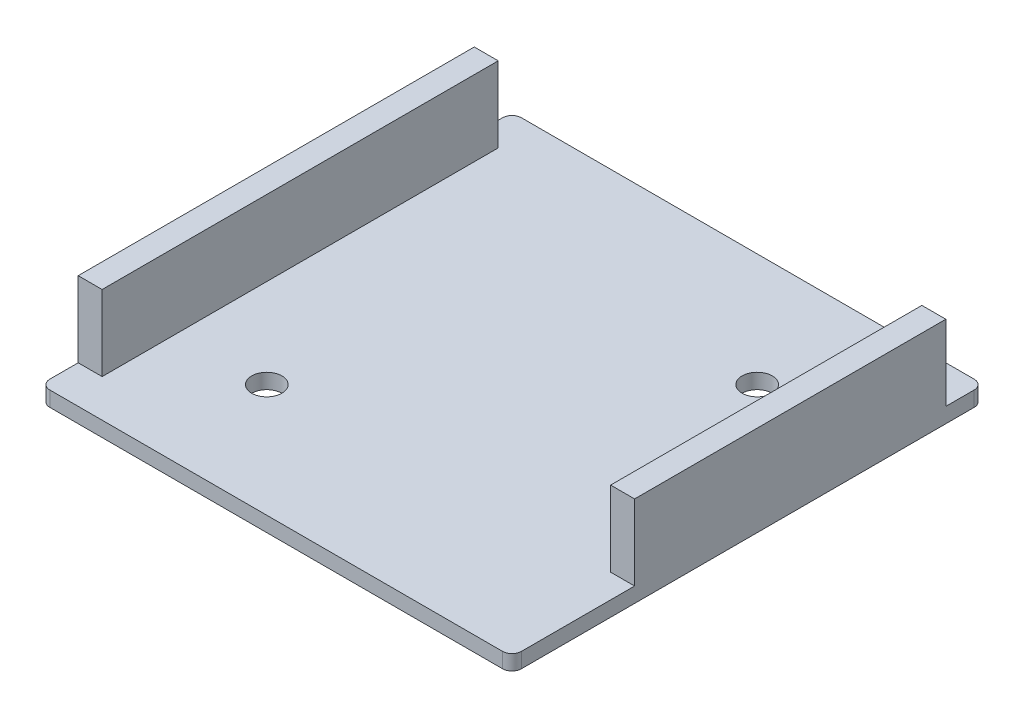
from build123d import *

# Parameters (mm, degrees)
SKETCH1_W           = 50
SKETCH1_H           = 50
BOSS_EXTRUDE1_DEPTH = 1.6
SKETCH2_R           = 1.6
CUT_EXTRUDE1_DEPTH  = 2.6
FILLET1_R           = 1
SKETCH3_W           = 2.54
SKETCH3_H           = 42
SKETCH3_H_2         = 33
BOSS_EXTRUDE2_DEPTH = 8


with BuildPart() as part:
    # Sketch1 → Boss-Extrude1 (new body)
    with BuildSketch(Plane(origin=(0, 0, 0), x_dir=(1, 0, 0), z_dir=(0, 1, 0))):
        Rectangle(SKETCH1_W, SKETCH1_H)
    extrude(amount=BOSS_EXTRUDE1_DEPTH)

    # Sketch2 → Cut-Extrude1 (cut, through all)
    with BuildSketch(Plane(origin=(0, 1.6, 0), x_dir=(1, 0, 0), z_dir=(0, 1, 0))):
        with Locations((-13, -13)):
            Circle(SKETCH2_R)
        with Locations((13, 13)):
            Circle(SKETCH2_R)
    extrude(amount=-CUT_EXTRUDE1_DEPTH, mode=Mode.SUBTRACT)

    # Fillet1
    fillet1_edges = [part.edges().sort_by_distance(p)[0] for p in [
        (-25, 0.8, -25),
        (25, 0.8, -25),
        (25, 0.8, 25),
        (-25, 0.8, 25),
    ]]
    fillet(fillet1_edges, radius=FILLET1_R)

    # Sketch3 → Boss-Extrude2 (add)
    with BuildSketch(Plane(origin=(0, 1.6, 0), x_dir=(1, 0, 0), z_dir=(0, 1, 0))):
        with Locations((-23.73, 0)):
            Rectangle(SKETCH3_W, SKETCH3_H)
        with Locations((23.73, 4.5)):
            Rectangle(SKETCH3_W, SKETCH3_H_2)
    extrude(amount=BOSS_EXTRUDE2_DEPTH)


solid = part.part
